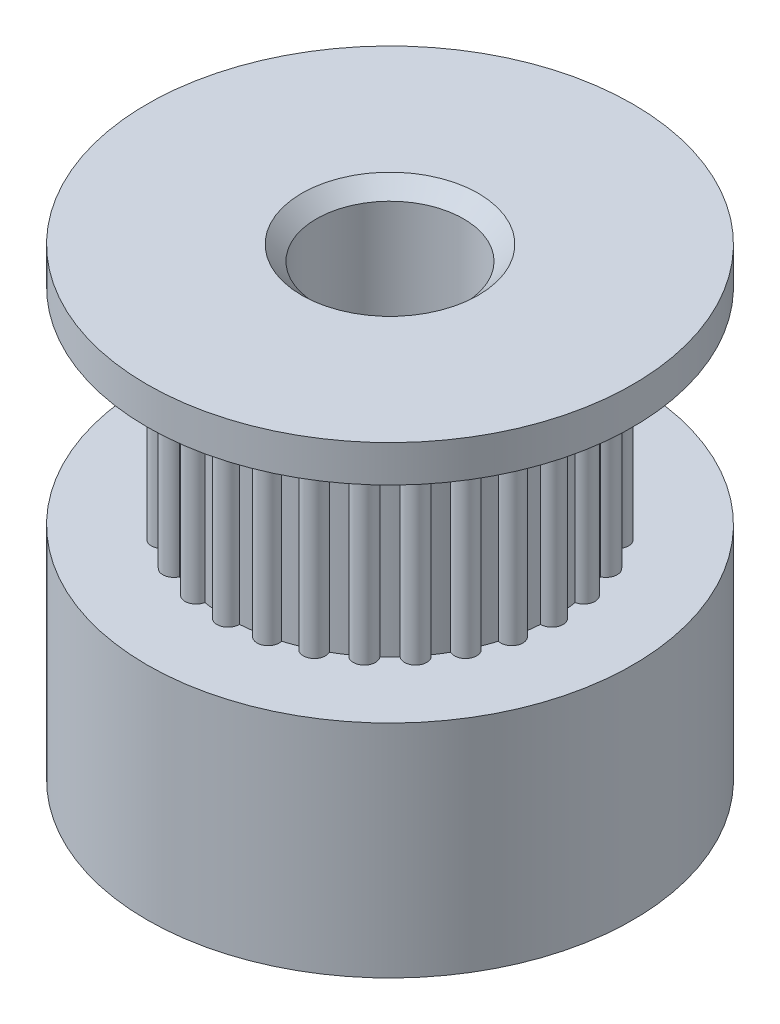
from build123d import *

# Parameters (mm, degrees)
SKETCH1_R               = 8.382
BOSS_EXTRUDE1_DEPTH     = 7.62
SKETCH2_R               = 5.588
BOSS_EXTRUDE2_DEPTH     = 7.112
SKETCH3_R               = 8.382
BOSS_EXTRUDE3_DEPTH     = 1.27
SKETCH4_R               = 2.54
CUT_EXTRUDE1_DEPTH      = 1
CUT_EXTRUDE1_DEPTH_BACK = 17.002
CHAMFER1_SIZE           = 0.508
SKETCH5_R               = 1.651
CUT_EXTRUDE2_DEPTH      = 9.382


with BuildPart() as part:
    # Sketch1 → Boss-Extrude1 (new body)
    with BuildSketch(Plane(origin=(0, 0, 0), x_dir=(1, 0, 0), z_dir=(0, 1, 0))):
        Circle(SKETCH1_R)
    extrude(amount=-BOSS_EXTRUDE1_DEPTH)

    # Sketch2 → Boss-Extrude2 (add)
    with BuildSketch(Plane(origin=(0, 0, 0), x_dir=(1, 0, 0), z_dir=(0, 1, 0))):
        with BuildLine():
            ThreePointArc((-4.121307864, 3.77366738), (-4.666752119, 3.721610627), (-4.596130935, 3.178258081))
            ThreePointArc((-4.596130935, 3.178258081), (-4.368874324, 3.484061013), (-4.121307864, 3.77366738))
        make_face()
        with BuildLine():
            ThreePointArc((-4.857698061, 2.761976385), (-5.377883173, 2.589852039), (-5.188125293, 2.075837167))
            ThreePointArc((-5.188125293, 2.075837167), (-5.034614034, 2.424542334), (-4.857698061, 2.761976385))
        make_face()
        with BuildLine():
            ThreePointArc((-5.350502993, 1.611788361), (-5.819344708, 1.328227455), (-5.519965385, 0.86932511))
            ThreePointArc((-5.519965385, 0.86932511), (-5.447897173, 1.243446979), (-5.350502993, 1.611788361))
        make_face()
        with BuildLine():
            ThreePointArc((-5.575011364, 0.380778538), (-5.969, 0), (-5.575011364, -0.380778538))
            ThreePointArc((-5.575011364, -0.380778538), (-5.588, 0), (-5.575011364, 0.380778538))
        make_face()
        with BuildLine():
            ThreePointArc((-5.350502993, -1.611788361), (-5.447897173, -1.243446979), (-5.519965385, -0.86932511))
            ThreePointArc((-5.519965385, -0.86932511), (-5.819344708, -1.328227455), (-5.350502993, -1.611788361))
        make_face()
        with BuildLine():
            ThreePointArc((-4.857698061, -2.761976385), (-5.034614034, -2.424542334), (-5.188125293, -2.075837167))
            ThreePointArc((-5.188125293, -2.075837167), (-5.377883173, -2.589852039), (-4.857698061, -2.761976385))
        make_face()
        with BuildLine():
            ThreePointArc((-4.121307864, -3.77366738), (-4.368874324, -3.484061013), (-4.596130935, -3.178258081))
            ThreePointArc((-4.596130935, -3.178258081), (-4.666752119, -3.721610627), (-4.121307864, -3.77366738))
        make_face()
        with BuildLine():
            ThreePointArc((-2.075837167, -5.188125293), (-2.424542334, -5.034614034), (-2.761976385, -4.857698061))
            ThreePointArc((-2.761976385, -4.857698061), (-2.589852039, -5.377883173), (-2.075837167, -5.188125293))
        make_face()
        with BuildLine():
            ThreePointArc((-0.86932511, -5.519965385), (-1.243446979, -5.447897173), (-1.611788361, -5.350502993))
            ThreePointArc((-1.611788361, -5.350502993), (-1.328227455, -5.819344708), (-0.86932511, -5.519965385))
        make_face()
        with BuildLine():
            ThreePointArc((2.761976385, -4.857698061), (2.424542334, -5.034614034), (2.075837167, -5.188125293))
            ThreePointArc((2.075837167, -5.188125293), (2.589852039, -5.377883173), (2.761976385, -4.857698061))
        make_face()
        with BuildLine():
            ThreePointArc((3.77366738, -4.121307864), (3.484061013, -4.368874324), (3.178258081, -4.596130935))
            ThreePointArc((3.178258081, -4.596130935), (3.721610627, -4.666752119), (3.77366738, -4.121307864))
        make_face()
        with BuildLine():
            ThreePointArc((4.596130935, -3.178258081), (4.368874324, -3.484061013), (4.121307864, -3.77366738))
            ThreePointArc((4.121307864, -3.77366738), (4.666752119, -3.721610627), (4.596130935, -3.178258081))
        make_face()
        with BuildLine():
            ThreePointArc((5.188125293, -2.075837167), (5.034614034, -2.424542334), (4.857698061, -2.761976385))
            ThreePointArc((4.857698061, -2.761976385), (5.377883173, -2.589852039), (5.188125293, -2.075837167))
        make_face()
        with BuildLine():
            ThreePointArc((5.588, 0), (5.584751897, -0.1905), (5.575011364, -0.380778538))
            ThreePointArc((5.575011364, -0.380778538), (5.969, 0), (5.575011364, 0.380778538))
            ThreePointArc((5.575011364, 0.380778538), (5.584751897, 0.1905), (5.588, 0))
        make_face()
        with BuildLine():
            ThreePointArc((5.519965385, 0.86932511), (5.819344708, 1.328227455), (5.350502993, 1.611788361))
            ThreePointArc((5.350502993, 1.611788361), (5.447897173, 1.243446979), (5.519965385, 0.86932511))
        make_face()
        with BuildLine():
            ThreePointArc((5.188125293, 2.075837167), (5.377883173, 2.589852039), (4.857698061, 2.761976385))
            ThreePointArc((4.857698061, 2.761976385), (5.034614034, 2.424542334), (5.188125293, 2.075837167))
        make_face()
        with BuildLine():
            ThreePointArc((4.596130935, 3.178258081), (4.666752119, 3.721610627), (4.121307864, 3.77366738))
            ThreePointArc((4.121307864, 3.77366738), (4.368874324, 3.484061013), (4.596130935, 3.178258081))
        make_face()
        with BuildLine():
            ThreePointArc((3.77366738, 4.121307864), (3.721610627, 4.666752119), (3.178258081, 4.596130935))
            ThreePointArc((3.178258081, 4.596130935), (3.484061013, 4.368874324), (3.77366738, 4.121307864))
        make_face()
        with BuildLine():
            ThreePointArc((2.761976385, 4.857698061), (2.589852039, 5.377883173), (2.075837167, 5.188125293))
            ThreePointArc((2.075837167, 5.188125293), (2.424542334, 5.034614034), (2.761976385, 4.857698061))
        make_face()
        with BuildLine():
            ThreePointArc((1.611788361, 5.350502993), (1.328227455, 5.819344708), (0.86932511, 5.519965385))
            ThreePointArc((0.86932511, 5.519965385), (1.243446979, 5.447897173), (1.611788361, 5.350502993))
        make_face()
        with BuildLine():
            ThreePointArc((0.380778538, 5.575011364), (0, 5.969), (-0.380778538, 5.575011364))
            ThreePointArc((-0.380778538, 5.575011364), (0, 5.588), (0.380778538, 5.575011364))
        make_face()
        with BuildLine():
            ThreePointArc((-0.86932511, 5.519965385), (-1.328227455, 5.819344708), (-1.611788361, 5.350502993))
            ThreePointArc((-1.611788361, 5.350502993), (-1.243446979, 5.447897173), (-0.86932511, 5.519965385))
        make_face()
        with BuildLine():
            ThreePointArc((-2.075837167, 5.188125293), (-2.589852039, 5.377883173), (-2.761976385, 4.857698061))
            ThreePointArc((-2.761976385, 4.857698061), (-2.424542334, 5.034614034), (-2.075837167, 5.188125293))
        make_face()
        with BuildLine():
            ThreePointArc((-3.178258081, 4.596130935), (-3.721610627, 4.666752119), (-3.77366738, 4.121307864))
            ThreePointArc((-3.77366738, 4.121307864), (-3.484061013, 4.368874324), (-3.178258081, 4.596130935))
        make_face()
        with BuildLine():
            ThreePointArc((-3.178258081, -4.596130935), (-3.484061013, -4.368874324), (-3.77366738, -4.121307864))
            ThreePointArc((-3.77366738, -4.121307864), (-3.721610627, -4.666752119), (-3.178258081, -4.596130935))
        make_face()
        with BuildLine():
            ThreePointArc((0.380778538, -5.575011364), (0, -5.588), (-0.380778538, -5.575011364))
            ThreePointArc((-0.380778538, -5.575011364), (0, -5.969), (0.380778538, -5.575011364))
        make_face()
        with BuildLine():
            ThreePointArc((1.611788361, -5.350502993), (1.243446979, -5.447897173), (0.86932511, -5.519965385))
            ThreePointArc((0.86932511, -5.519965385), (1.328227455, -5.819344708), (1.611788361, -5.350502993))
        make_face()
        with BuildLine():
            ThreePointArc((5.519965385, -0.86932511), (5.447897173, -1.243446979), (5.350502993, -1.611788361))
            ThreePointArc((5.350502993, -1.611788361), (5.819344708, -1.328227455), (5.519965385, -0.86932511))
        make_face()
        Circle(SKETCH2_R)
    extrude(amount=BOSS_EXTRUDE2_DEPTH)

    # Sketch3 → Boss-Extrude3 (add)
    with BuildSketch(Plane(origin=(0, 7.112, 0), x_dir=(1, 0, 0), z_dir=(0, 1, 0))):
        Circle(SKETCH3_R)
    extrude(amount=BOSS_EXTRUDE3_DEPTH)

    # Sketch4 → Cut-Extrude1 (cut, two sides)
    with BuildSketch(Plane.XZ.offset(7.62)) as cut_extrude1_sk:
        Circle(SKETCH4_R)
    extrude(amount=CUT_EXTRUDE1_DEPTH, mode=Mode.SUBTRACT)
    extrude(cut_extrude1_sk.sketch, amount=-CUT_EXTRUDE1_DEPTH_BACK, mode=Mode.SUBTRACT)

    # Chamfer1
    chamfer1_edges = [part.edges().sort_by_distance(p)[0] for p in [
        (-2.54, 8.382, 0),
        (-2.54, -7.62, 0),
    ]]
    chamfer(chamfer1_edges, length=CHAMFER1_SIZE)

    # Sketch5 → Cut-Extrude2 (cut, through all)
    with BuildSketch(Plane(origin=(0, 0, 0), x_dir=(0, 0, -1), z_dir=(1, 0, 0))):
        with Locations((0, -3.81)):
            Circle(SKETCH5_R)
    extrude(amount=-CUT_EXTRUDE2_DEPTH, mode=Mode.SUBTRACT)


solid = part.part
